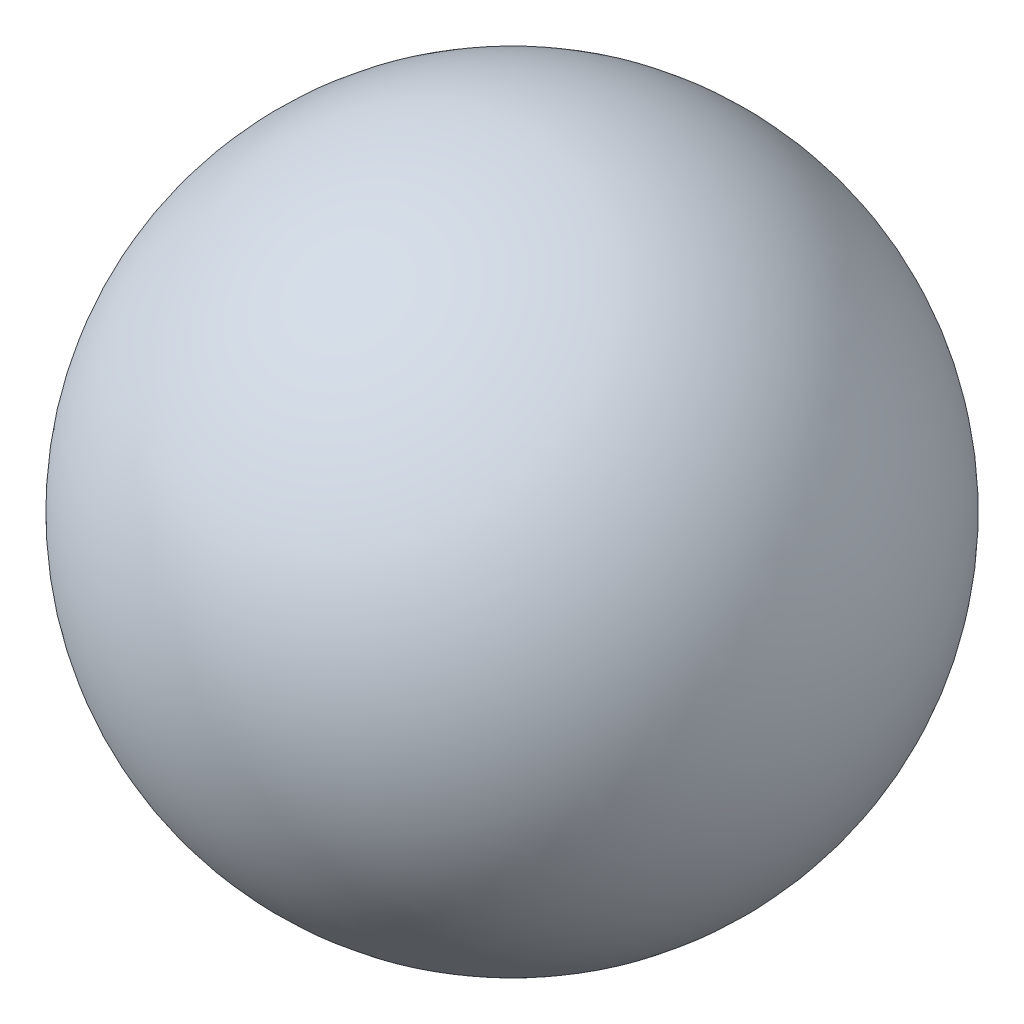
from build123d import *


with BuildPart() as part:
    # Sketch1 → Revolve3 (revolve)
    with BuildSketch(Plane.XY):
        with BuildLine():
            Line((0, 3.65782753), (0, -4.94217247))
            ThreePointArc((0, -4.94217247), (4.3, -0.64217247), (0, 3.65782753))
        make_face()
    revolve(axis=Axis((0, 3.65782753, 0), (0, -1, 0)))


solid = part.part
